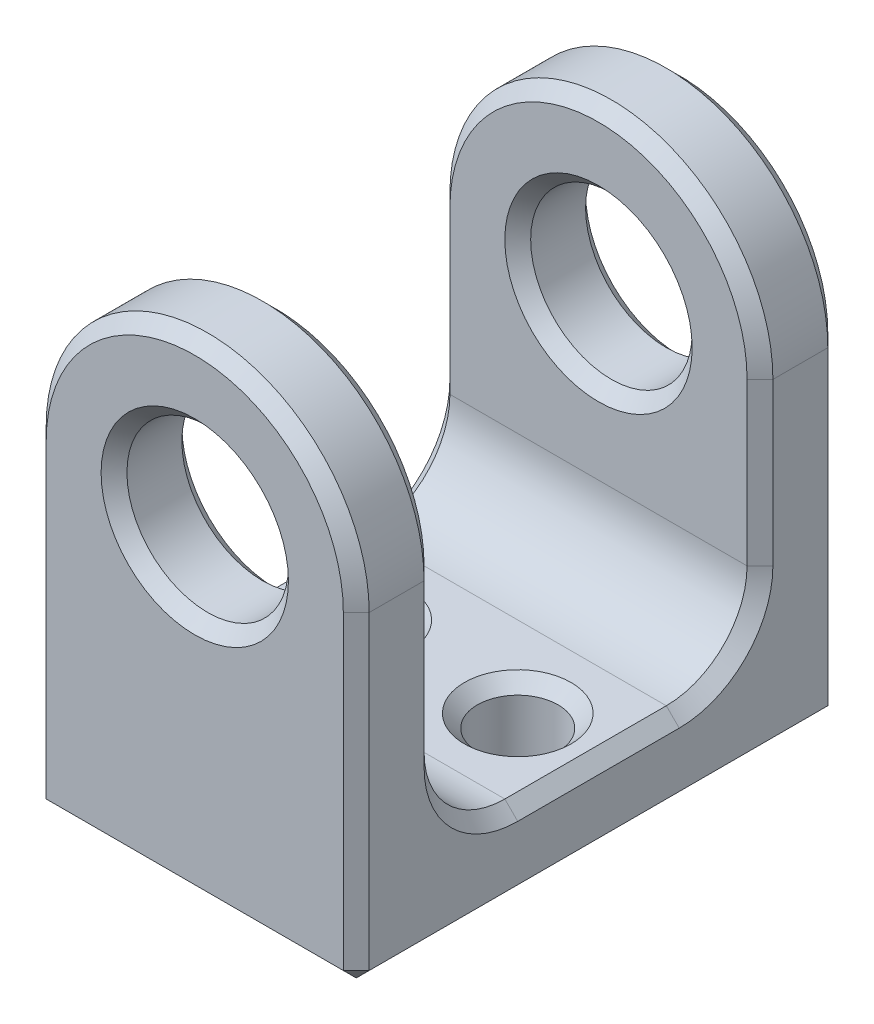
from build123d import *

# Parameters (mm, degrees)
SKETCH1_R                    = 3.175
BOSS_EXTRUDE1_DEPTH          = 9.525
SKETCH2_W                    = 12.7
SKETCH2_H                    = 15.875
CUT_EXTRUDE1_DEPTH           = 7.35
CUT_EXTRUDE1_DEPTH_BACK      = 7.35
F_1_8_0_125_DIAMETER_HOLE1_D = 3.175
FILLET2_R                    = 3.175
CHAMFER1_SIZE                = 0.508


with BuildPart() as part:
    # Sketch1 → Boss-Extrude1 (new body, symmetric)
    with BuildSketch(Plane.XY):
        with BuildLine():
            Line((-6.35, 0), (-6.35, -12.7))
            Line((-6.35, -12.7), (6.35, -12.7))
            Line((6.35, -12.7), (6.35, 0))
            ThreePointArc((6.35, 0), (0, 6.35), (-6.35, 0))
        make_face()
        Circle(SKETCH1_R, mode=Mode.SUBTRACT)
    extrude(amount=BOSS_EXTRUDE1_DEPTH, both=True)

    # Sketch2 → Cut-Extrude1 (cut, two sides)
    with BuildSketch(Plane(origin=(0, 0, 0), x_dir=(0, 0, -1), z_dir=(1, 0, 0))) as cut_extrude1_sk:
        with Locations((0, -1.5875)):
            Rectangle(SKETCH2_W, SKETCH2_H)
    extrude(amount=CUT_EXTRUDE1_DEPTH, mode=Mode.SUBTRACT)
    extrude(cut_extrude1_sk.sketch, amount=-CUT_EXTRUDE1_DEPTH_BACK, mode=Mode.SUBTRACT)

    # 1/8 (0.125) Diameter Hole1 (through all)
    with Locations(Plane(origin=(0, -9.525, 0), x_dir=(1, 0, 0), z_dir=(0, 1, 0))):
        with Locations((-3.175, 0), (3.175, 0)):
            Hole(F_1_8_0_125_DIAMETER_HOLE1_D / 2)

    # Fillet2
    fillet2_edges = [part.edges().sort_by_distance(p)[0] for p in [
        (0, -9.525, 6.35),
        (0, -9.525, -6.35),
    ]]
    fillet(fillet2_edges, radius=FILLET2_R)

    # Chamfer1
    chamfer1_edges = [part.edges().sort_by_distance(p)[0] for p in [
        (-6.35, -6.35, 9.525),
        (-3.175, 0, -9.525),
        (-3.175, 0, 9.525),
        (0, -12.7, 9.525),
        (0, 6.35, 6.35),
        (-6.35, -3.175, 6.35),
        (-3.175, 0, 6.35),
        (-3.175, 0, -6.35),
        (6.35, -3.175, -6.35),
        (0, 6.35, -6.35),
        (-6.35, -3.175, -6.35),
        (6.35, -3.175, 6.35),
        (6.35, -6.35, 9.525),
        (0, -12.7, -9.525),
        (4.7625, -9.525, 0),
        (4.7625, -12.7, 0),
        (-6.35, -6.35, -9.525),
        (-1.5875, -9.525, 0),
        (-1.5875, -12.7, 0),
        (0, 6.35, -9.525),
        (-6.35, -9.525, 0),
        (6.35, -9.525, 0),
        (6.35, -6.35, -9.525),
        (6.35, -8.59506403, -5.42006403),
        (-6.35, -8.59506403, -5.42006403),
        (6.35, -8.59506403, 5.42006403),
        (-6.35, -8.59506403, 5.42006403),
        (0, 6.35, 9.525),
        (6.35, -12.7, 0),
        (-6.35, -12.7, 0),
    ]]
    chamfer(chamfer1_edges, length=CHAMFER1_SIZE)


solid = part.part
